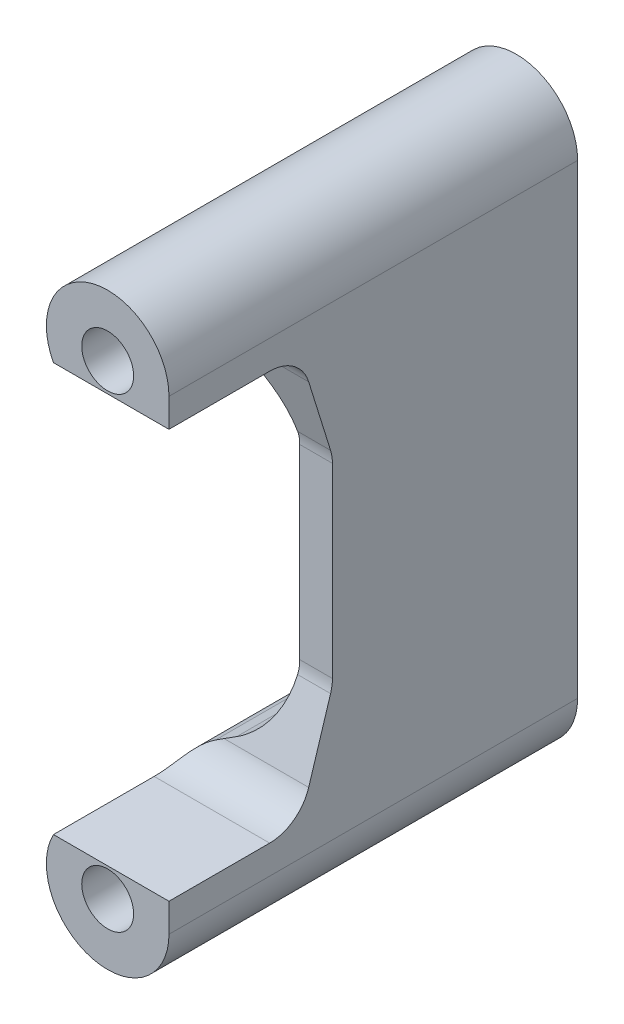
from build123d import *

# Parameters (mm, degrees)
CROQUIS1_R              = 3.175
SALIENTE_EXTRUIR1_DEPTH = 25
REDONDEO1_R             = 10
CORTAR_EXTRUIR1_DEPTH   = 16
REDONDEO2_R             = 5


with BuildPart() as part:
    # Croquis1 → Saliente-Extruir1 (new body, symmetric)
    with BuildSketch(Plane.XY):
        with BuildLine():
            Line((-4, 17.843284464), (-11.233642387, 21.995392823))
            ThreePointArc((-11.233642387, 21.995392823), (-11.258169907, 34.990466775), (0, 28.5))
            Line((0, 28.5), (0, -28.5))
            ThreePointArc((0, -28.5), (-11.258169907, -34.990466775), (-11.233642387, -21.995392823))
            Line((-11.233642387, -21.995392823), (-4, -17.843284464))
            Line((-4, -17.843284464), (-4, 17.843284464))
        make_face()
        with Locations((-7.5, 28.5)):
            Circle(CROQUIS1_R, mode=Mode.SUBTRACT)
        with Locations((-7.5, -28.5)):
            Circle(CROQUIS1_R, mode=Mode.SUBTRACT)
    extrude(amount=SALIENTE_EXTRUIR1_DEPTH, both=True)

    # Redondeo1
    redondeo1_edges = [part.edges().sort_by_distance(p)[0] for p in [
        (-4, -17.843284464, 0),
        (-4, 17.843284464, 0),
    ]]
    fillet(redondeo1_edges, radius=REDONDEO1_R)

    # Croquis2 → Cortar-Extruir1 (cut, through all)
    with BuildSketch(Plane(origin=(0, 0, 0), x_dir=(0, 0, -1), z_dir=(1, 0, 0))):
        Polygon((-9, 25), (-5, 12.159257653), (-5, -12.159257653), (-9, -25), (-29.873538988, -25), (-29.873538988, 25), align=None)
    extrude(amount=-CORTAR_EXTRUIR1_DEPTH, mode=Mode.SUBTRACT)

    # Redondeo2
    redondeo2_edges = [part.edges().sort_by_distance(p)[0] for p in [
        (-2.000282316, 12.159257653, 5),
        (-2.000282316, -12.159257653, 5),
        (-7.06662479, -25, 9),
        (-7.06662479, 25, 9),
    ]]
    fillet(redondeo2_edges, radius=REDONDEO2_R)


solid = part.part
